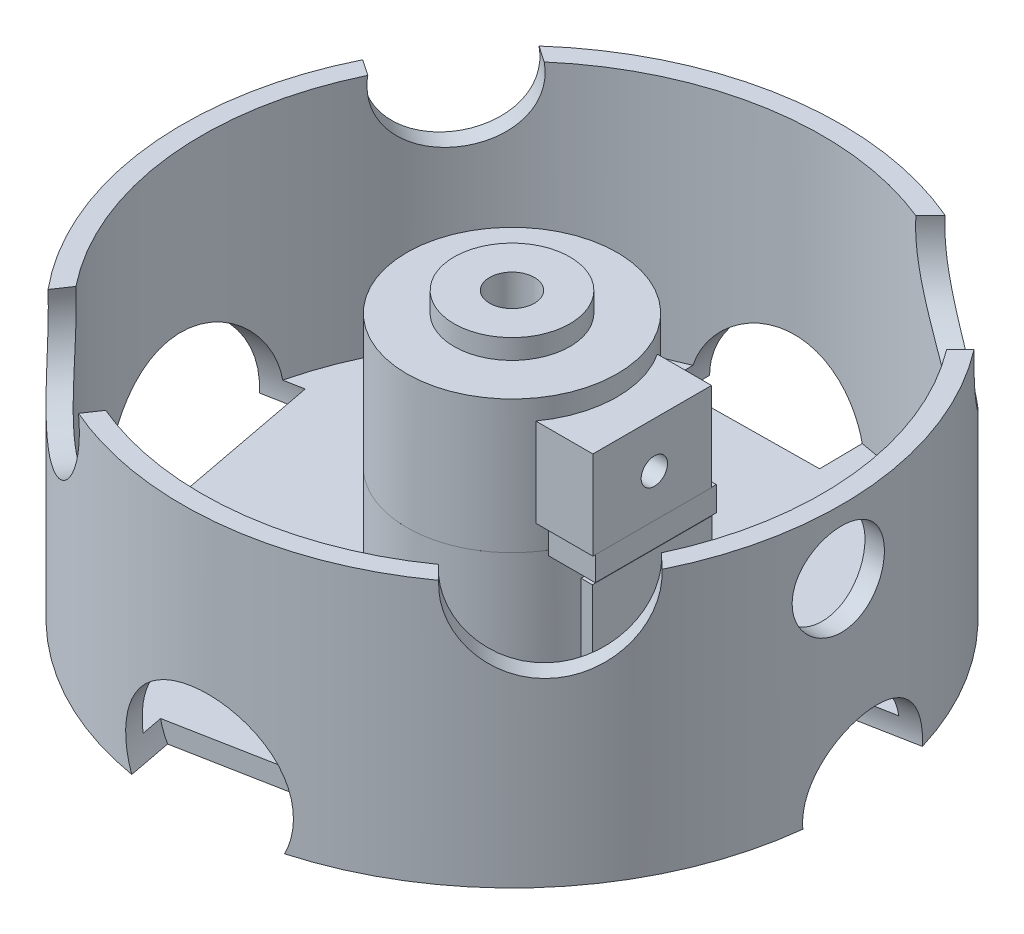
from build123d import *

# Parameters (mm, degrees)
SKETCH1_R                      = 15.958
SHAFTHOLDERNEARMOTOR_DEPTH     = 20.19
SKETCH2_R                      = 3.4
CUT_EXTRUDE1_DEPTH             = 16.85
SKETCH5_W                      = 1.550685
SKETCH5_H                      = 7.184216
BOSS_EXTRUDE2_DEPTH            = 13.55
SKETCH7_W                      = 18.003976
SKETCH7_H                      = 13.433491
BOSS_EXTRUDE3_DEPTH            = 19
SKETCH6_R                      = 2
CUT_EXTRUDE2_DEPTH             = 1
CUT_EXTRUDE2_DEPTH_BACK        = 19
SKETCH9_W                      = 7.520011
SKETCH9_H                      = 9.493348
NUTOPENING_DEPTH               = 30
SKETCH10_R                     = 50
BOSS_EXTRUDE4_DEPTH            = 20
SKETCH12_R                     = 47.082764
SKETCH12_R_2                   = 15.957901
CUTTOREMVEEXCESSMATERIAL_DEPTH = 17
SKETCH13_R                     = 50
SKETCH13_R_2                   = 47.082764
BOSS_EXTRUDE5_DEPTH            = 20
CUT_EXTRUDE6_DEPTH             = 7.520012
SKETCH16_R                     = 7
CUT_EXTRUDE7_DEPTH             = 40
SKETCH19_R                     = 12
CUT_EXTRUDE8_DEPTH             = 10
SKETCH20_R                     = 12
CUT_EXTRUDE9_DEPTH             = 10
SKETCH22_R                     = 12.553525
CUT_EXTRUDE10_DEPTH            = 10
SKETCH21_R                     = 10
CUT_EXTRUDE11_DEPTH            = 10
SKETCH23_R                     = 11.965333
CUT_EXTRUDE12_DEPTH            = 10
SKETCH25_R                     = 9.629681
CUT_EXTRUDE13_DEPTH            = 10
SKETCH26_R                     = 15.012411
CUT_EXTRUDE14_DEPTH            = 10
SKETCH27_R                     = 11.854712
CUT_EXTRUDE15_DEPTH            = 10
SKETCH28_W                     = 1.716797
SKETCH28_H                     = 18.172416
BOSS_EXTRUDE6_DEPTH            = 17
SKETCH29_W                     = 7.058522
SKETCH29_H                     = 18.363906
BOSS_EXTRUDE7_DEPTH            = 3.722722
SKETCH30_R                     = 8.787565
SKETCH30_R_2                   = 3.4
EXTRASHAFTSUPPORT_DEPTH        = 3


with BuildPart() as part:
    # Sketch1 → ShaftHolderNearMotor (new body)
    with BuildSketch(Plane(origin=(0, 0, 0), x_dir=(1, 0, 0), z_dir=(0, 1, 0))):
        Circle(SKETCH1_R)
    extrude(amount=SHAFTHOLDERNEARMOTOR_DEPTH)

    # Sketch2 → Cut-Extrude1 (cut)
    with BuildSketch(Plane(origin=(0, 20.19, 0), x_dir=(1, 0, 0), z_dir=(0, 1, 0))):
        Circle(SKETCH2_R)
    extrude(amount=-CUT_EXTRUDE1_DEPTH, mode=Mode.SUBTRACT)

    # Sketch5 → Boss-Extrude2 (add)
    with BuildSketch(Plane(origin=(0, 15.15, 0), x_dir=(1, 0, 0), z_dir=(0, 1, 0))):
        with Locations((3.375343, 0.02052)):
            Rectangle(SKETCH5_W, SKETCH5_H)
    extrude(amount=-BOSS_EXTRUDE2_DEPTH)

    # Sketch7 → Boss-Extrude3 (add)
    with BuildSketch(Plane.ZY.offset(-2.6)):
        with Locations((0.330272, 10.439467)):
            Rectangle(SKETCH7_W, SKETCH7_H)
    extrude(amount=-BOSS_EXTRUDE3_DEPTH)

    # Sketch6 → Cut-Extrude2 (cut, two sides)
    with BuildSketch(Plane.ZY.offset(-2.6)) as cut_extrude2_sk:
        with Locations((0, 10.236926)):
            Circle(SKETCH6_R)
    extrude(amount=CUT_EXTRUDE2_DEPTH, mode=Mode.SUBTRACT)
    extrude(cut_extrude2_sk.sketch, amount=-CUT_EXTRUDE2_DEPTH_BACK, mode=Mode.SUBTRACT)

    # Sketch9 → NutOpening (cut)
    with BuildSketch(Plane.XY):
        with Locations((8.412034, 10.235527)):
            Rectangle(SKETCH9_W, SKETCH9_H)
    extrude(amount=-NUTOPENING_DEPTH, mode=Mode.SUBTRACT)

    # Sketch10 → Boss-Extrude4 (add)
    with BuildSketch(Plane.XZ):
        Circle(SKETCH10_R)
    extrude(amount=BOSS_EXTRUDE4_DEPTH)

    # Sketch12 → CutToRemveExcessMaterial (cut)
    with BuildSketch(Plane(origin=(0, 0, 0), x_dir=(1, 0, 0), z_dir=(0, 1, 0))):
        Circle(SKETCH12_R)
        Circle(SKETCH12_R_2, mode=Mode.SUBTRACT)
    extrude(amount=-CUTTOREMVEEXCESSMATERIAL_DEPTH, mode=Mode.SUBTRACT)

    # Sketch13 → Boss-Extrude5 (add)
    with BuildSketch(Plane(origin=(0, 0, 0), x_dir=(1, 0, 0), z_dir=(0, 1, 0))):
        Circle(SKETCH13_R)
        Circle(SKETCH13_R_2, mode=Mode.SUBTRACT)
    extrude(amount=BOSS_EXTRUDE5_DEPTH)

    # Sketch14 → Cut-Extrude6 (cut)
    with BuildSketch(Plane.ZY.offset(-12.17204)):
        Polygon((-5.454124, 10.236926), (-2.727062, 5.513515), (2.727062, 5.513515), (5.454124, 10.236926), (2.727062, 14.960336), (-2.727062, 14.960336), align=None)
    extrude(amount=CUT_EXTRUDE6_DEPTH, mode=Mode.SUBTRACT)

    # Sketch16 → Cut-Extrude7 (cut)
    with BuildSketch(Plane(origin=(21.6, 0, 0), x_dir=(0, 0, -1), z_dir=(1, 0, 0))):
        with Locations((0, 10.236926)):
            Circle(SKETCH16_R)
    extrude(amount=CUT_EXTRUDE7_DEPTH, mode=Mode.SUBTRACT)

    # Sketch19 → Cut-Extrude8 (cut)
    with BuildSketch(Plane(origin=(9.351145, 0, 49.117778), x_dir=(0.982356, 0, -0.187023), z_dir=(0.187023, 0, 0.982356))):
        with Locations((-6.553799, -15.044376)):
            Circle(SKETCH19_R)
    extrude(amount=-CUT_EXTRUDE8_DEPTH, mode=Mode.SUBTRACT)

    # Sketch20 → Cut-Extrude9 (cut)
    with BuildSketch(Plane(origin=(35.756785, 0, 34.949282), x_dir=(0.698986, 0, -0.715136), z_dir=(0.715136, 0, 0.698986))):
        with Locations((3.558366, 19.429209)):
            Circle(SKETCH20_R)
    extrude(amount=-CUT_EXTRUDE9_DEPTH, mode=Mode.SUBTRACT)

    # Sketch22 → Cut-Extrude10 (cut)
    with BuildSketch(Plane(origin=(34.949282, 0, -35.756785), x_dir=(-0.715136, 0, -0.698986), z_dir=(0.698986, 0, -0.715136))):
        with Locations((5.427738, 18.490794)):
            Circle(SKETCH22_R)
    extrude(amount=-CUT_EXTRUDE10_DEPTH, mode=Mode.SUBTRACT)

    # Sketch21 → Cut-Extrude11 (cut)
    with BuildSketch(Plane(origin=(49.117778, 0, -9.351145), x_dir=(-0.187023, 0, -0.982356), z_dir=(0.982356, 0, -0.187023))):
        with Locations((-4.791176, -19.221883)):
            Circle(SKETCH21_R)
    extrude(amount=-CUT_EXTRUDE11_DEPTH, mode=Mode.SUBTRACT)

    # Sketch23 → Cut-Extrude12 (cut)
    with BuildSketch(Plane(origin=(-0.570991, 0, -49.99674), x_dir=(-0.999935, 0, 0.01142), z_dir=(-0.01142, 0, -0.999935))):
        with Locations((4.525184, -20.01777)):
            Circle(SKETCH23_R)
    extrude(amount=-CUT_EXTRUDE12_DEPTH, mode=Mode.SUBTRACT)

    # Sketch25 → Cut-Extrude13 (cut)
    with BuildSketch(Plane(origin=(-41.343772, 0, -28.119255), x_dir=(-0.562385, 0, 0.826875), z_dir=(-0.826875, 0, -0.562385))):
        with Locations((-2.649824, 18.643159)):
            Circle(SKETCH25_R)
    extrude(amount=-CUT_EXTRUDE13_DEPTH, mode=Mode.SUBTRACT)

    # Sketch26 → Cut-Extrude14 (cut)
    with BuildSketch(Plane(origin=(-49.117778, 0, 9.351145), x_dir=(0.187023, 0, 0.982356), z_dir=(-0.982356, 0, 0.187023))):
        with Locations((-4.497651, -19.126377)):
            Circle(SKETCH26_R)
    extrude(amount=-CUT_EXTRUDE14_DEPTH, mode=Mode.SUBTRACT)

    # Sketch27 → Cut-Extrude15 (cut)
    with BuildSketch(Plane(origin=(-28.119255, 0, 41.343772), x_dir=(0.826875, 0, 0.562385), z_dir=(-0.562385, 0, 0.826875))):
        with Locations((-2.287517, 17.622181)):
            Circle(SKETCH27_R)
    extrude(amount=-CUT_EXTRUDE15_DEPTH, mode=Mode.SUBTRACT)

    # Sketch28 → Boss-Extrude6 (add)
    with BuildSketch(Plane.XZ):
        with Locations((20.741601, 0.317955)):
            Rectangle(SKETCH28_W, SKETCH28_H)
    extrude(amount=BOSS_EXTRUDE6_DEPTH)

    # Sketch29 → Boss-Extrude7 (add)
    with BuildSketch(Plane.XZ.offset(-3.722722)):
        with Locations((18.019415, -0.266361)):
            Rectangle(SKETCH29_W, SKETCH29_H)
    extrude(amount=BOSS_EXTRUDE7_DEPTH)

    # Sketch30 → ExtraShaftSupport (add)
    with BuildSketch(Plane(origin=(0, 20.19, 0), x_dir=(1, 0, 0), z_dir=(0, 1, 0))):
        Circle(SKETCH30_R)
        Circle(SKETCH30_R_2, mode=Mode.SUBTRACT)
    extrude(amount=EXTRASHAFTSUPPORT_DEPTH)


solid = part.part
